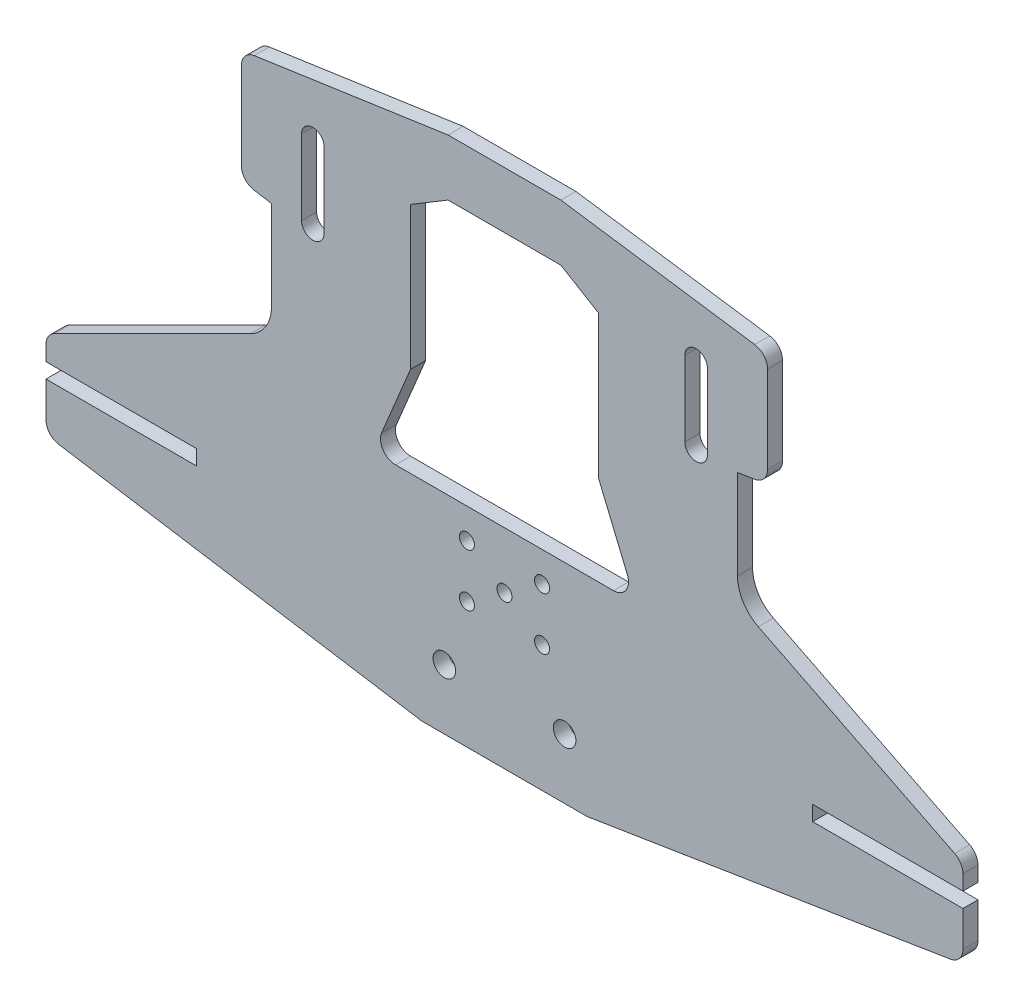
from build123d import *

# Parameters (mm, degrees)
RESSALTO_EXTRUS_O1_DEPTH = 2
ESBO_O2_R                = 1
ESBO_O2_R_2              = 1.5
ESBO_O2_W                = 20
ESBO_O2_H                = 2
CORTE_EXTRUS_O1_DEPTH    = 3


with BuildPart() as part:
    # Esboço1 → Ressalto-extrusão1 (new body)
    with BuildSketch(Plane.XY):
        with BuildLine():
            Line((0, 0), (11, 0))
            Line((11, 0), (59.315981002, 7.73055696))
            ThreePointArc((59.315981002, 7.73055696), (60.521834749, 8.407740649), (61, 9.705438224))
            Line((61, 9.705438224), (61, 18.403988486))
            ThreePointArc((61, 18.403988486), (60.701301617, 19.45545071), (59.894427191, 20.192842868))
            Line((59.894427191, 20.192842868), (33.763932023, 33.258090452))
            ThreePointArc((33.763932023, 33.258090452), (31.746745958, 35.101570847), (31, 37.730226407))
            Line((31, 37.730226407), (31, 49.640056464))
            Line((31, 49.640056464), (33.315981002, 50.010613424))
            ThreePointArc((33.315981002, 50.010613424), (34.521834749, 50.687797112), (35, 51.985494688))
            Line((35, 51.985494688), (35, 63.549919266))
            ThreePointArc((35, 63.549919266), (34.512573863, 64.858399418), (33.287879691, 65.529092145))
            Line((33.287879691, 65.529092145), (7.5, 69.280056464))
            Line((7.5, 69.280056464), (0, 69.280056464))
            Line((0, 69.280056464), (0, 61.780056464))
            Line((0, 61.780056464), (7.5, 61.780056464))
            Line((7.5, 61.780056464), (12.5, 58.780056464))
            Line((12.5, 58.780056464), (12.5, 39.780056464))
            Line((12.5, 39.780056464), (16.346153846, 30.549287233))
            ThreePointArc((16.346153846, 30.549287233), (16.164100589, 28.670656071), (14.5, 27.780056464))
            Line((14.5, 27.780056464), (0, 27.780056464))
            Line((0, 27.780056464), (0, 0))
        make_face()
    ressalto_extrus_o1 = extrude(amount=RESSALTO_EXTRUS_O1_DEPTH)

    # Espelhar1: Ressalto-extrusão1 across plane
    add(ressalto_extrus_o1.mirror(Plane(origin=(0, 0, 0), x_dir=(0, 0, 1), z_dir=(1, 0, 0))))

    # Esboço2 → Corte-extrusão1 (cut, through all)
    with BuildSketch(Plane.XY.offset(2)):
        with Locations((-5, 23.780056464)):
            Circle(ESBO_O2_R)
        with Locations((5, 23.780056464)):
            Circle(ESBO_O2_R)
        with Locations((5, 16.780056464)):
            Circle(ESBO_O2_R)
        with Locations((-5, 16.780056464)):
            Circle(ESBO_O2_R)
        with Locations((0, 20.280056464)):
            Circle(ESBO_O2_R)
        with Locations((-8, 8)):
            Circle(ESBO_O2_R_2)
        with Locations((8, 8)):
            Circle(ESBO_O2_R_2)
        with BuildLine():
            Line((-24, 59.661874645), (-24, 49.661874645))
            ThreePointArc((-24, 49.661874645), (-25.5, 48.161874645), (-27, 49.661874645))
            Line((-27, 49.661874645), (-27, 59.661874645))
            ThreePointArc((-27, 59.661874645), (-25.5, 61.161874645), (-24, 59.661874645))
        make_face()
        with BuildLine():
            Line((24, 59.661874645), (24, 49.661874645))
            ThreePointArc((24, 49.661874645), (25.5, 48.161874645), (27, 49.661874645))
            Line((27, 49.661874645), (27, 59.661874645))
            ThreePointArc((27, 59.661874645), (25.5, 61.161874645), (24, 59.661874645))
        make_face()
        with Locations((-51, 15.407740649)):
            Rectangle(ESBO_O2_W, ESBO_O2_H)
        with Locations((51, 15.407740649)):
            Rectangle(ESBO_O2_W, ESBO_O2_H)
    extrude(amount=-CORTE_EXTRUS_O1_DEPTH, mode=Mode.SUBTRACT)


solid = part.part
